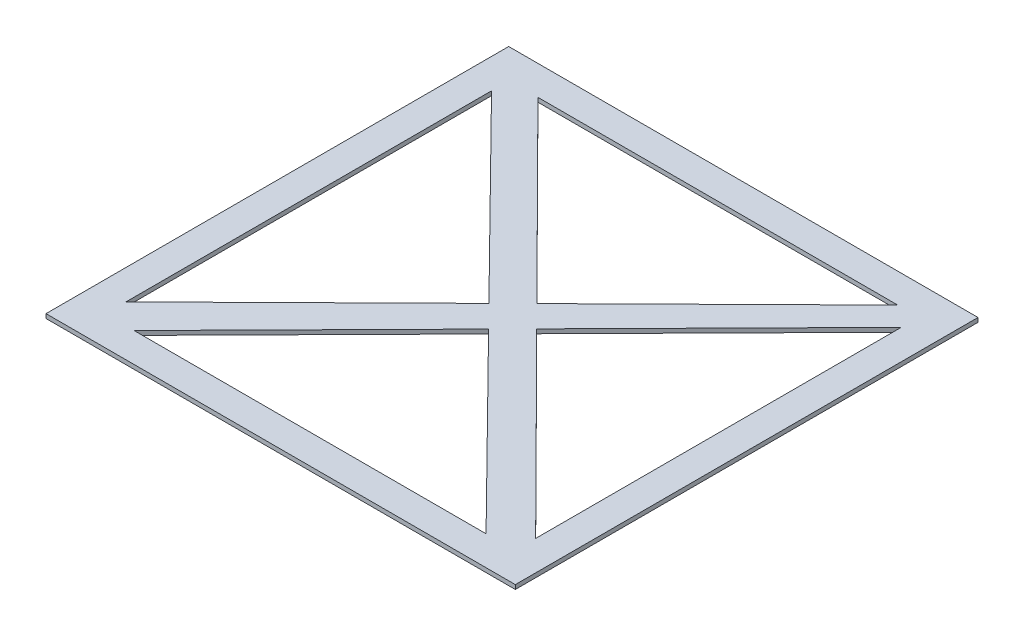
from build123d import *

# Parameters (mm, degrees)
SKETCH_5_W      = 2209.965574324
SKETCH_5_H      = 2178.657088224
EXTRUDE_1_DEPTH = 20


with BuildPart() as part:
    # 草图5 → 凸台-拉伸1 (new body)
    with BuildSketch(Plane(origin=(0, 0, 0), x_dir=(1, 0, 0), z_dir=(0, 1, 0))):
        with Locations((-201.363960341, -118.642097246)):
            Rectangle(SKETCH_5_W, SKETCH_5_H)
        Polygon((-1165.926599204, 749.551468133), (-305.329028983, -123.413356765), (-1165.926599204, -971.818878667), align=None, mode=Mode.SUBTRACT)
        Polygon((-1030.12162171, 832.255624695), (664.07343499, 832.255624695), (-191.599463217, -11.294992808), align=None, mode=Mode.SUBTRACT)
        Polygon((-88.80991437, -114.700951165), (763.198678521, 749.551468133), (763.198678521, -971.818878667), align=None, mode=Mode.SUBTRACT)
        Polygon((-201.363960341, -228.872459931), (-1030.12162171, -1069.539819188), (627.393701027, -1069.539819188), align=None, mode=Mode.SUBTRACT)
    extrude(amount=EXTRUDE_1_DEPTH)


solid = part.part
